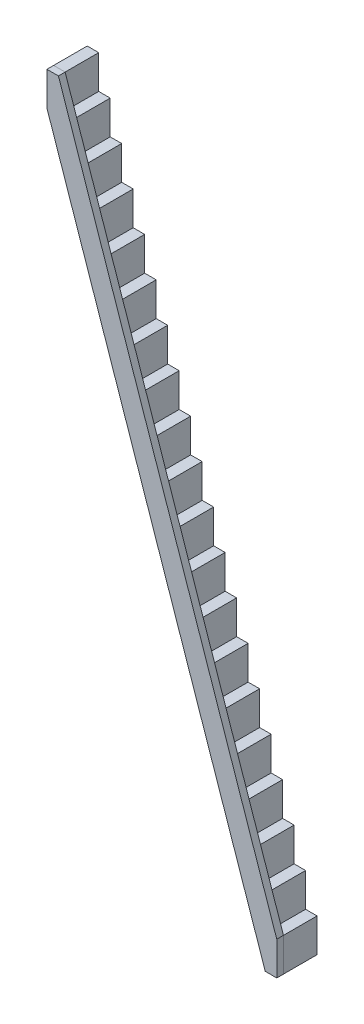
from build123d import *

# Parameters (mm, degrees)
SKETCH2_W              = 1.71
SKETCH2_H              = 5
BOSS_EXTRUDE2_DEPTH    = 5
BOSS_EXTRUDE2_2_DEPTH  = 5
BOSS_EXTRUDE2_3_DEPTH  = 5
BOSS_EXTRUDE2_4_DEPTH  = 5
BOSS_EXTRUDE2_5_DEPTH  = 5
BOSS_EXTRUDE2_6_DEPTH  = 5
BOSS_EXTRUDE2_7_DEPTH  = 5
BOSS_EXTRUDE2_8_DEPTH  = 5
BOSS_EXTRUDE2_9_DEPTH  = 5
BOSS_EXTRUDE2_10_DEPTH = 5
BOSS_EXTRUDE2_11_DEPTH = 5
BOSS_EXTRUDE2_12_DEPTH = 5
BOSS_EXTRUDE2_13_DEPTH = 5
BOSS_EXTRUDE2_14_DEPTH = 5
BOSS_EXTRUDE2_15_DEPTH = 5
BOSS_EXTRUDE2_16_DEPTH = 5
BOSS_EXTRUDE2_17_DEPTH = 5
BOSS_EXTRUDE2_18_DEPTH = 5
BOSS_EXTRUDE2_19_DEPTH = 5
BOSS_EXTRUDE2_20_DEPTH = 5
BOSS_EXTRUDE6_DEPTH    = 1


with BuildPart() as part:
    # Sketch2 → Boss-Extrude2 (new body)
    with BuildSketch(Plane.XY):
        with Locations((-3.643043478, -1.905108696)):
            Rectangle(SKETCH2_W, SKETCH2_H)
    extrude(amount=BOSS_EXTRUDE2_DEPTH)


with BuildPart() as body_2:
    # Sketch2 → Boss-Extrude2 2 (new body)
    with BuildSketch(Plane.XY):
        with Locations((-5.353043478, 3.094891304)):
            Rectangle(SKETCH2_W, SKETCH2_H)
    extrude(amount=BOSS_EXTRUDE2_2_DEPTH)


with BuildPart() as body_3:
    # Sketch2 → Boss-Extrude2 3 (new body)
    with BuildSketch(Plane.XY):
        with Locations((-7.063043478, 8.094891304)):
            Rectangle(SKETCH2_W, SKETCH2_H)
    extrude(amount=BOSS_EXTRUDE2_3_DEPTH)


with BuildPart() as body_4:
    # Sketch2 → Boss-Extrude2 4 (new body)
    with BuildSketch(Plane.XY):
        with Locations((-8.773043478, 13.094891304)):
            Rectangle(SKETCH2_W, SKETCH2_H)
    extrude(amount=BOSS_EXTRUDE2_4_DEPTH)


with BuildPart() as body_5:
    # Sketch2 → Boss-Extrude2 5 (new body)
    with BuildSketch(Plane.XY):
        with Locations((-10.483043478, 18.094891304)):
            Rectangle(SKETCH2_W, SKETCH2_H)
    extrude(amount=BOSS_EXTRUDE2_5_DEPTH)


with BuildPart() as body_6:
    # Sketch2 → Boss-Extrude2 6 (new body)
    with BuildSketch(Plane.XY):
        with Locations((-12.193043478, 23.094891304)):
            Rectangle(SKETCH2_W, SKETCH2_H)
    extrude(amount=BOSS_EXTRUDE2_6_DEPTH)


with BuildPart() as body_7:
    # Sketch2 → Boss-Extrude2 7 (new body)
    with BuildSketch(Plane.XY):
        with Locations((-13.903043478, 28.094891304)):
            Rectangle(SKETCH2_W, SKETCH2_H)
    extrude(amount=BOSS_EXTRUDE2_7_DEPTH)


with BuildPart() as body_8:
    # Sketch2 → Boss-Extrude2 8 (new body)
    with BuildSketch(Plane.XY):
        with Locations((-15.613043478, 33.094891304)):
            Rectangle(SKETCH2_W, SKETCH2_H)
    extrude(amount=BOSS_EXTRUDE2_8_DEPTH)


with BuildPart() as body_9:
    # Sketch2 → Boss-Extrude2 9 (new body)
    with BuildSketch(Plane.XY):
        with Locations((-17.323043478, 38.094891304)):
            Rectangle(SKETCH2_W, SKETCH2_H)
    extrude(amount=BOSS_EXTRUDE2_9_DEPTH)


with BuildPart() as body_10:
    # Sketch2 → Boss-Extrude2 10 (new body)
    with BuildSketch(Plane.XY):
        with Locations((-19.033043478, 43.094891304)):
            Rectangle(SKETCH2_W, SKETCH2_H)
    extrude(amount=BOSS_EXTRUDE2_10_DEPTH)


with BuildPart() as body_11:
    # Sketch2 → Boss-Extrude2 11 (new body)
    with BuildSketch(Plane.XY):
        with Locations((-20.743043478, 48.094891304)):
            Rectangle(SKETCH2_W, SKETCH2_H)
    extrude(amount=BOSS_EXTRUDE2_11_DEPTH)


with BuildPart() as body_12:
    # Sketch2 → Boss-Extrude2 12 (new body)
    with BuildSketch(Plane.XY):
        with Locations((-22.453043478, 53.094891304)):
            Rectangle(SKETCH2_W, SKETCH2_H)
    extrude(amount=BOSS_EXTRUDE2_12_DEPTH)


with BuildPart() as body_13:
    # Sketch2 → Boss-Extrude2 13 (new body)
    with BuildSketch(Plane.XY):
        with Locations((-24.163043478, 58.094891304)):
            Rectangle(SKETCH2_W, SKETCH2_H)
    extrude(amount=BOSS_EXTRUDE2_13_DEPTH)


with BuildPart() as body_14:
    # Sketch2 → Boss-Extrude2 14 (new body)
    with BuildSketch(Plane.XY):
        with Locations((-25.873043478, 63.094891304)):
            Rectangle(SKETCH2_W, SKETCH2_H)
    extrude(amount=BOSS_EXTRUDE2_14_DEPTH)


with BuildPart() as body_15:
    # Sketch2 → Boss-Extrude2 15 (new body)
    with BuildSketch(Plane.XY):
        with Locations((-27.583043478, 68.094891304)):
            Rectangle(SKETCH2_W, SKETCH2_H)
    extrude(amount=BOSS_EXTRUDE2_15_DEPTH)


with BuildPart() as body_16:
    # Sketch2 → Boss-Extrude2 16 (new body)
    with BuildSketch(Plane.XY):
        with Locations((-29.293043478, 73.094891304)):
            Rectangle(SKETCH2_W, SKETCH2_H)
    extrude(amount=BOSS_EXTRUDE2_16_DEPTH)


with BuildPart() as body_17:
    # Sketch2 → Boss-Extrude2 17 (new body)
    with BuildSketch(Plane.XY):
        with Locations((-31.003043478, 78.094891304)):
            Rectangle(SKETCH2_W, SKETCH2_H)
    extrude(amount=BOSS_EXTRUDE2_17_DEPTH)


with BuildPart() as body_18:
    # Sketch2 → Boss-Extrude2 18 (new body)
    with BuildSketch(Plane.XY):
        with Locations((-32.713043478, 83.094891304)):
            Rectangle(SKETCH2_W, SKETCH2_H)
    extrude(amount=BOSS_EXTRUDE2_18_DEPTH)


with BuildPart() as body_19:
    # Sketch2 → Boss-Extrude2 19 (new body)
    with BuildSketch(Plane.XY):
        with Locations((-34.423043478, 88.094891304)):
            Rectangle(SKETCH2_W, SKETCH2_H)
    extrude(amount=BOSS_EXTRUDE2_19_DEPTH)


with BuildPart() as body_20:
    # Sketch2 → Boss-Extrude2 20 (new body)
    with BuildSketch(Plane.XY):
        with Locations((-36.133043478, 93.094891304)):
            Rectangle(SKETCH2_W, SKETCH2_H)
    extrude(amount=BOSS_EXTRUDE2_20_DEPTH)


with BuildPart() as body_21:
    # Sketch3 → Boss-Extrude6 (new body)
    with BuildSketch(Plane.XY.offset(5)):
        Polygon((-36.988043478, 90.594891304), (-4.498043478, -4.405108696), (-2.788043478, -4.405108696), (-2.788043478, 0.594891304), (-35.278043478, 95.594891304), (-36.988043478, 95.594891304), align=None)
    extrude(amount=BOSS_EXTRUDE6_DEPTH)


solid = Compound([part.part, body_2.part, body_3.part, body_4.part, body_5.part, body_6.part, body_7.part, body_8.part, body_9.part, body_10.part, body_11.part, body_12.part, body_13.part, body_14.part, body_15.part, body_16.part, body_17.part, body_18.part, body_19.part, body_20.part, body_21.part])
